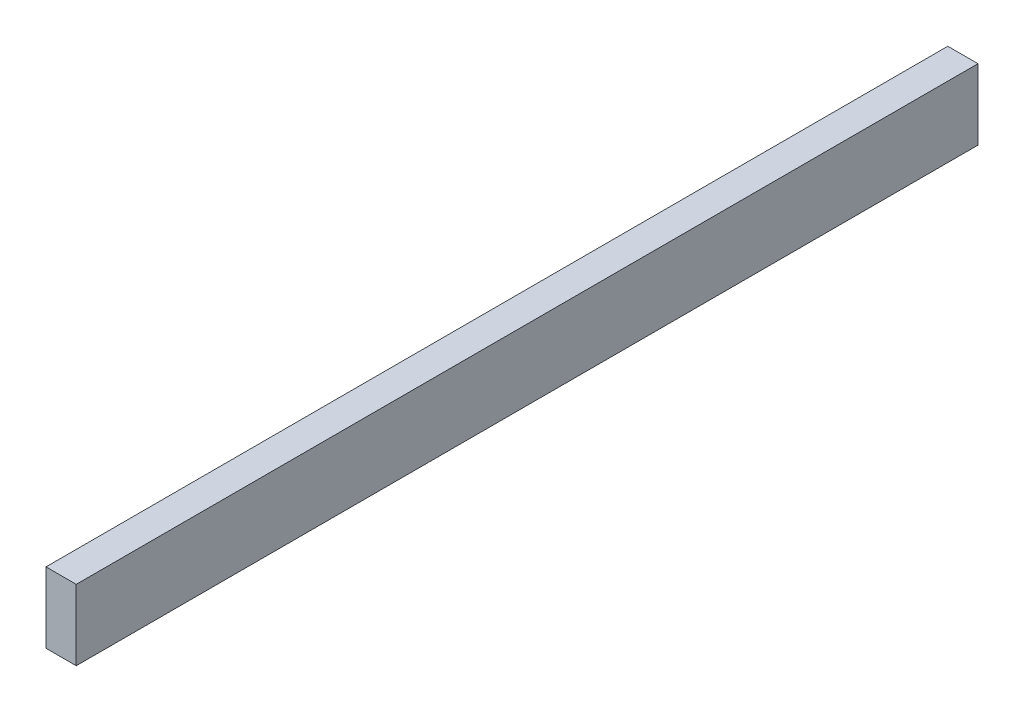
from build123d import *

# Parameters (mm, degrees)
SKETCH1_W           = 38.1
SKETCH1_H           = 88.9
BOSS_EXTRUDE1_DEPTH = 1136.65


with BuildPart() as part:
    # Sketch1 → Boss-Extrude1 (new body)
    with BuildSketch(Plane.XY):
        with Locations((-19.05, 12.935364734)):
            Rectangle(SKETCH1_W, SKETCH1_H)
    extrude(amount=BOSS_EXTRUDE1_DEPTH)


solid = part.part
